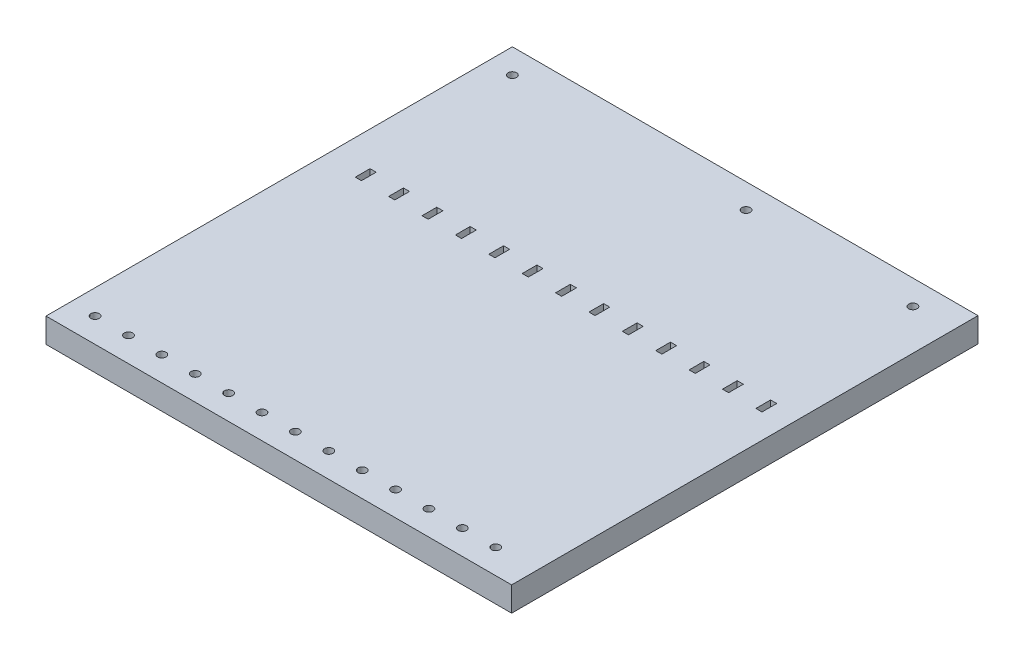
from build123d import *

# Parameters (mm, degrees)
SKETCH1_W           = 189.7
SKETCH1_H           = 190
SKETCH1_R           = 1.7
SKETCH1_W_2         = 2.5
SKETCH1_H_2         = 6
BOSS_EXTRUDE1_DEPTH = 10


with BuildPart() as part:
    # Sketch1 → Boss-Extrude1 (new body)
    with BuildSketch(Plane(origin=(0, 0, 0), x_dir=(1, 0, 0), z_dir=(0, 1, 0))):
        with Locations((84.85, 85)):
            Rectangle(SKETCH1_W, SKETCH1_H)
        Circle(SKETCH1_R, mode=Mode.SUBTRACT)
        with Locations((0, 170)):
            Circle(SKETCH1_R, mode=Mode.SUBTRACT)
        with Locations((13.6, 0)):
            Circle(SKETCH1_R, mode=Mode.SUBTRACT)
        with Locations((27.2, 0)):
            Circle(SKETCH1_R, mode=Mode.SUBTRACT)
        with Locations((40.8, 0)):
            Circle(SKETCH1_R, mode=Mode.SUBTRACT)
        with Locations((54.4, 0)):
            Circle(SKETCH1_R, mode=Mode.SUBTRACT)
        with Locations((68, 0)):
            Circle(SKETCH1_R, mode=Mode.SUBTRACT)
        with Locations((81.6, 0)):
            Circle(SKETCH1_R, mode=Mode.SUBTRACT)
        with Locations((95.2, 0)):
            Circle(SKETCH1_R, mode=Mode.SUBTRACT)
        with Locations((108.8, 0)):
            Circle(SKETCH1_R, mode=Mode.SUBTRACT)
        with Locations((122.4, 0)):
            Circle(SKETCH1_R, mode=Mode.SUBTRACT)
        with Locations((136, 0)):
            Circle(SKETCH1_R, mode=Mode.SUBTRACT)
        with Locations((149.6, 0)):
            Circle(SKETCH1_R, mode=Mode.SUBTRACT)
        with Locations((163.2, 0)):
            Circle(SKETCH1_R, mode=Mode.SUBTRACT)
        with Locations((95.2, 170)):
            Circle(SKETCH1_R, mode=Mode.SUBTRACT)
        with Locations((163.2, 170)):
            Circle(SKETCH1_R, mode=Mode.SUBTRACT)
        with Locations((5.25, 105)):
            Rectangle(SKETCH1_W_2, SKETCH1_H_2, mode=Mode.SUBTRACT)
        with Locations((18.85, 105)):
            Rectangle(SKETCH1_W_2, SKETCH1_H_2, mode=Mode.SUBTRACT)
        with Locations((32.45, 105)):
            Rectangle(SKETCH1_W_2, SKETCH1_H_2, mode=Mode.SUBTRACT)
        with Locations((46.05, 105)):
            Rectangle(SKETCH1_W_2, SKETCH1_H_2, mode=Mode.SUBTRACT)
        with Locations((59.65, 105)):
            Rectangle(SKETCH1_W_2, SKETCH1_H_2, mode=Mode.SUBTRACT)
        with Locations((73.25, 105)):
            Rectangle(SKETCH1_W_2, SKETCH1_H_2, mode=Mode.SUBTRACT)
        with Locations((86.85, 105)):
            Rectangle(SKETCH1_W_2, SKETCH1_H_2, mode=Mode.SUBTRACT)
        with Locations((100.45, 105)):
            Rectangle(SKETCH1_W_2, SKETCH1_H_2, mode=Mode.SUBTRACT)
        with Locations((114.05, 105)):
            Rectangle(SKETCH1_W_2, SKETCH1_H_2, mode=Mode.SUBTRACT)
        with Locations((127.65, 105)):
            Rectangle(SKETCH1_W_2, SKETCH1_H_2, mode=Mode.SUBTRACT)
        with Locations((141.25, 105)):
            Rectangle(SKETCH1_W_2, SKETCH1_H_2, mode=Mode.SUBTRACT)
        with Locations((154.85, 105)):
            Rectangle(SKETCH1_W_2, SKETCH1_H_2, mode=Mode.SUBTRACT)
        with Locations((168.45, 105)):
            Rectangle(SKETCH1_W_2, SKETCH1_H_2, mode=Mode.SUBTRACT)
    extrude(amount=-BOSS_EXTRUDE1_DEPTH)


solid = part.part
